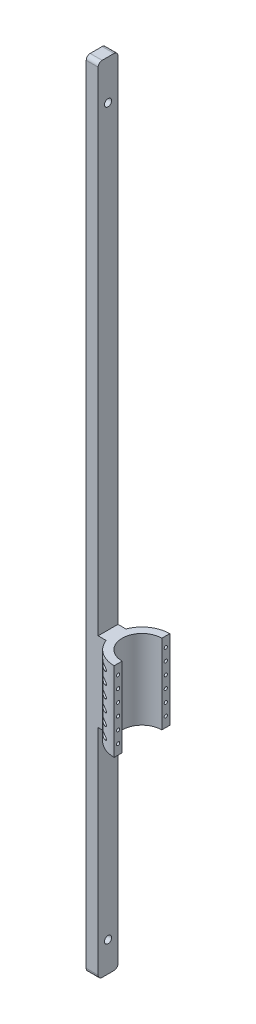
from build123d import *

# Parameters (mm, degrees)
Y_KSEKLIK_EKSTR_ZYON2_DEPTH = 400
Y_KSEKLIK_EKSTR_ZYON3_DEPTH = 60
IZIM6_R                     = 8
KES_EKSTR_ZYON1_DEPTH       = 30
IZIM7_R                     = 8
KES_EKSTR_ZYON2_DEPTH       = 30
IZIM10_R                    = 12
KES_EKSTR_ZYON6_DEPTH       = 170
IZIM11_R                    = 18
KES_EKSTR_ZYON7_DEPTH       = 80
IZIM12_R                    = 18
KES_EKSTR_ZYON8_DEPTH       = 60
IZIM14_R                    = 18
KES_EKSTR_ZYON9_DEPTH       = 128


with BuildPart() as part:
    # Çizim1 → Yükseklik-Ekstrüzyon2 (new body)
    with BuildSketch(Plane(origin=(0, 0, 0), x_dir=(1, 0, 0), z_dir=(0, 1, 0))):
        with BuildLine():
            Line((0, 140), (0, 100))
            ThreePointArc((0, 100), (-100, 0), (0, -100))
            Line((0, -100), (0, -140))
            ThreePointArc((0, -140), (-140, 0), (0, 140))
        make_face()
        with BuildLine():
            ThreePointArc((-130.766968306, -50), (-140, 0), (-130.766968306, 50))
            Line((-130.766968306, 50), (-170.766968306, 50))
            Line((-170.766968306, 50), (-170.766968306, -50))
            Line((-170.766968306, -50), (-130.766968306, -50))
        make_face()
    extrude(amount=Y_KSEKLIK_EKSTR_ZYON2_DEPTH)

    # Çizim5 → Yükseklik-Ekstrüzyon3 (add)
    with BuildSketch(Plane.ZY.offset(170.766968306)):
        with BuildLine():
            Line((50, 0), (50, 2880))
            ThreePointArc((50, 2880), (44.142135624, 2894.142135624), (30, 2900))
            Line((30, 2900), (-30, 2900))
            ThreePointArc((-30, 2900), (-44.142135624, 2894.142135624), (-50, 2880))
            Line((-50, 2880), (-50, -1080))
            ThreePointArc((-50, -1080), (-44.142135624, -1094.142135624), (-30, -1100))
            Line((-30, -1100), (30, -1100))
            ThreePointArc((30, -1100), (44.142135624, -1094.142135624), (50, -1080))
            Line((50, -1080), (50, 0))
        make_face()
    extrude(amount=Y_KSEKLIK_EKSTR_ZYON3_DEPTH)

    # Çizim6 → Kes-Ekstrüzyon1 (cut)
    with BuildSketch(Plane(origin=(0, 0, 0), x_dir=(0, 0, -1), z_dir=(1, 0, 0))):
        with Locations((-120, 350)):
            Circle(IZIM6_R)
        with Locations((-120, 290)):
            Circle(IZIM6_R)
        with Locations((-120, 230)):
            Circle(IZIM6_R)
        with Locations((-120, 170)):
            Circle(IZIM6_R)
        with Locations((-120, 110)):
            Circle(IZIM6_R)
        with Locations((-120, 50)):
            Circle(IZIM6_R)
    extrude(amount=-KES_EKSTR_ZYON1_DEPTH, mode=Mode.SUBTRACT)

    # Çizim7 → Kes-Ekstrüzyon2 (cut)
    with BuildSketch(Plane(origin=(0, 0, 0), x_dir=(0, 0, -1), z_dir=(1, 0, 0))):
        with Locations((120, 350)):
            Circle(IZIM7_R)
        with Locations((120, 290)):
            Circle(IZIM7_R)
        with Locations((120, 230)):
            Circle(IZIM7_R)
        with Locations((120, 170)):
            Circle(IZIM7_R)
        with Locations((120, 110)):
            Circle(IZIM7_R)
        with Locations((120, 50)):
            Circle(IZIM7_R)
    extrude(amount=-KES_EKSTR_ZYON2_DEPTH, mode=Mode.SUBTRACT)

    # Çizim10 → Kes-Ekstrüzyon6 (cut)
    with BuildSketch(Plane(origin=(-30, 0, 0), x_dir=(0, 0, -1), z_dir=(1, 0, 0))):
        with Locations((-120, 350)):
            Circle(IZIM10_R)
        with Locations((-120, 290)):
            Circle(IZIM10_R)
        with Locations((-120, 230)):
            Circle(IZIM10_R)
        with Locations((-120, 170)):
            Circle(IZIM10_R)
        with Locations((-120, 110)):
            Circle(IZIM10_R)
        with Locations((-120, 50)):
            Circle(IZIM10_R)
        with Locations((120, 50)):
            Circle(IZIM10_R)
        with Locations((120, 110)):
            Circle(IZIM10_R)
        with Locations((120, 170)):
            Circle(IZIM10_R)
        with Locations((120, 230)):
            Circle(IZIM10_R)
        with Locations((120, 290)):
            Circle(IZIM10_R)
        with Locations((120, 350)):
            Circle(IZIM10_R)
    extrude(amount=-KES_EKSTR_ZYON6_DEPTH, mode=Mode.SUBTRACT)

    # Çizim11 → Kes-Ekstrüzyon7 (cut)
    with BuildSketch(Plane.ZY.offset(230.766968306)):
        with Locations((0, 320)):
            Circle(IZIM11_R)
        with Locations((0, 200)):
            Circle(IZIM11_R)
        with Locations((0, 80)):
            Circle(IZIM11_R)
    extrude(amount=-KES_EKSTR_ZYON7_DEPTH, mode=Mode.SUBTRACT)

    # Çizim12 → Kes-Ekstrüzyon8 (cut)
    with BuildSketch(Plane.ZY.offset(230.766968306)):
        with Locations((0, -950)):
            Circle(IZIM12_R)
    extrude(amount=-KES_EKSTR_ZYON8_DEPTH, mode=Mode.SUBTRACT)

    # Çizim14 → Kes-Ekstrüzyon9 (cut)
    with BuildSketch(Plane.ZY.offset(230.766968306)):
        with Locations((0, 2700)):
            Circle(IZIM14_R)
    extrude(amount=-KES_EKSTR_ZYON9_DEPTH, mode=Mode.SUBTRACT)


solid = part.part
